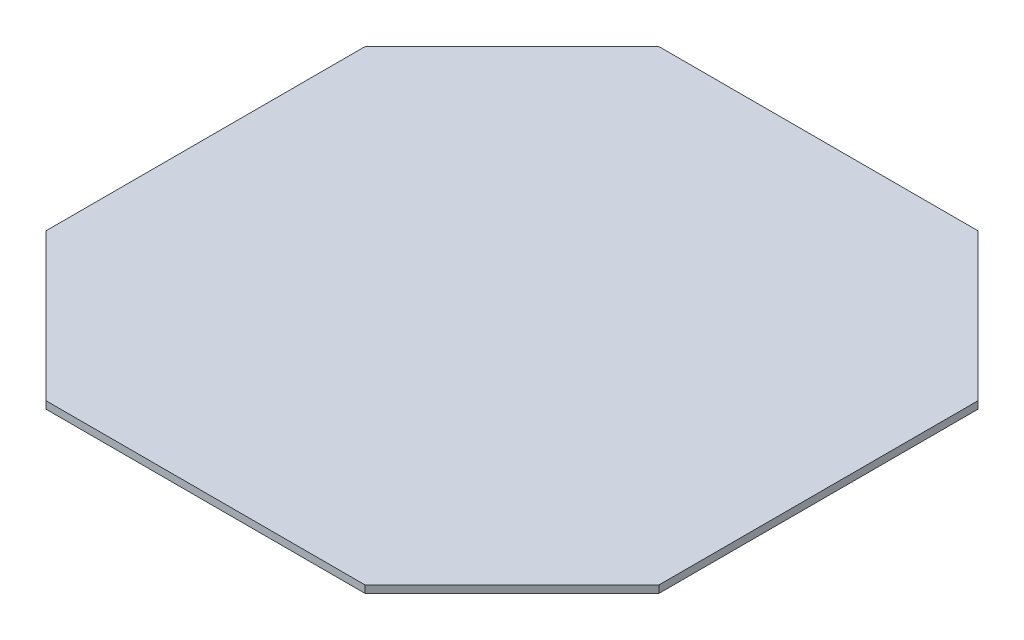
from build123d import *

# Parameters (mm, degrees)
ESQUISSE1_W       = 250
ESQUISSE1_H       = 250
EXTRUSION1_DEPTH  = 3
EXTRUSION11_DEPTH = 13


with BuildPart() as part:
    # Esquisse1 → Extrusion1 (new body)
    with BuildSketch(Plane(origin=(0, 0, 0), x_dir=(1, 0, 0), z_dir=(0, 1, 0))):
        Rectangle(ESQUISSE1_W, ESQUISSE1_H)
    extrude(amount=EXTRUSION1_DEPTH)

    # Esquisse2 → Extrusion11 (cut)
    with BuildSketch(Plane(origin=(0, 3, 0), x_dir=(1, 0, 0), z_dir=(0, 1, 0))):
        Polygon((-125, 125), (-125, 65), (-65, 125), align=None)
        Polygon((125, 125), (65, 125), (125, 65), align=None)
        Polygon((125, -65), (65, -125), (125, -125), align=None)
        Polygon((-65, -125), (-125, -65), (-125, -125), align=None)
    extrude(amount=-EXTRUSION11_DEPTH, mode=Mode.SUBTRACT)


solid = part.part
